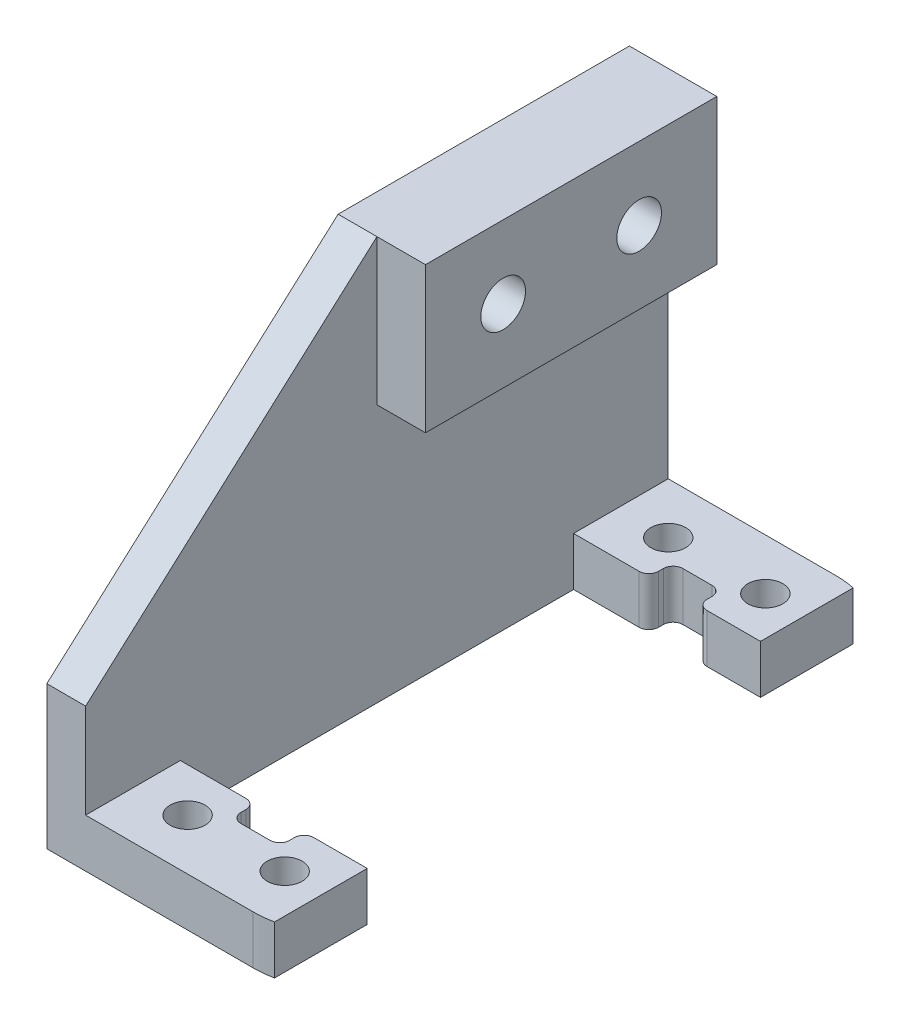
from build123d import *

# Parameters (mm, degrees)
SKETCH1_W           = 50
SKETCH1_H           = 60
BOSS_EXTRUDE1_DEPTH = 5
SKETCH2_W           = 20.5
SKETCH2_H           = 40.5
CUT_EXTRUDE1_DEPTH  = 5
SKETCH3_R           = 1.8
CUT_EXTRUDE2_DEPTH  = 5
SKETCH4_R           = 2.5
CUT_EXTRUDE3_DEPTH  = 5
FILLET1_R           = 10
SKETCH5_W           = 5
SKETCH5_H           = 5
CUT_EXTRUDE4_DEPTH  = 10
FILLET2_R           = 1
SKETCH6_W           = 17.943789306
SKETCH6_H           = 60
CUT_EXTRUDE5_DEPTH  = 10
SKETCH7_W           = 4
SKETCH7_H           = 60
BOSS_EXTRUDE2_DEPTH = 36.6
SKETCH8_W           = 21.864927769
SKETCH8_H           = 69.948880873
CUT_EXTRUDE6_DEPTH  = 24
SKETCH9_W           = 30
SKETCH9_H           = 15
BOSS_EXTRUDE3_DEPTH = 5
CUT_EXTRUDE7_DEPTH  = 5
SKETCH11_R          = 2.3
CUT_EXTRUDE8_DEPTH  = 13


with BuildPart() as part:
    # Sketch1 → Boss-Extrude1 (new body)
    with BuildSketch(Plane(origin=(0, 0, 0), x_dir=(1, 0, 0), z_dir=(0, 1, 0))):
        Rectangle(SKETCH1_W, SKETCH1_H)
    extrude(amount=BOSS_EXTRUDE1_DEPTH)

    # Sketch2 → Cut-Extrude1 (cut)
    with BuildSketch(Plane(origin=(0, 5, 0), x_dir=(1, 0, 0), z_dir=(0, 1, 0))):
        with Locations((8, 0)):
            Rectangle(SKETCH2_W, SKETCH2_H)
    extrude(amount=-CUT_EXTRUDE1_DEPTH, mode=Mode.SUBTRACT)

    # Sketch3 → Cut-Extrude2 (cut)
    with BuildSketch(Plane(origin=(0, 5, 0), x_dir=(1, 0, 0), z_dir=(0, 1, 0))):
        with Locations((3, 24.75)):
            Circle(SKETCH3_R)
        with Locations((13, 24.75)):
            Circle(SKETCH3_R)
        with Locations((13, -24.75)):
            Circle(SKETCH3_R)
        with Locations((3, -24.75)):
            Circle(SKETCH3_R)
    extrude(amount=-CUT_EXTRUDE2_DEPTH, mode=Mode.SUBTRACT)

    # Sketch4 → Cut-Extrude3 (cut)
    with BuildSketch(Plane(origin=(0, 5, 0), x_dir=(1, 0, 0), z_dir=(0, 1, 0))):
        with Locations((-17.5, 20)):
            Circle(SKETCH4_R)
        with Locations((-17.5, -20)):
            Circle(SKETCH4_R)
    extrude(amount=-CUT_EXTRUDE3_DEPTH, mode=Mode.SUBTRACT)

    # Fillet1
    fillet1_edges = [part.edges().sort_by_distance(p)[0] for p in [
        (-25, 2.5, -30),
        (25, 2.5, -30),
        (25, 2.5, 30),
        (-25, 2.5, 30),
    ]]
    fillet(fillet1_edges, radius=FILLET1_R)

    # Sketch5 → Cut-Extrude4 (cut)
    with BuildSketch(Plane(origin=(0, 5, 0), x_dir=(1, 0, 0), z_dir=(0, 1, 0))):
        with Locations((8, 20.25)):
            Rectangle(SKETCH5_W, SKETCH5_H)
    cut_extrude4 = extrude(amount=-CUT_EXTRUDE4_DEPTH, mode=Mode.SUBTRACT)

    # Mirror1: Cut-Extrude4 across plane
    add(cut_extrude4.mirror(Plane.XY), mode=Mode.SUBTRACT)

    # Fillet2
    fillet2_edges = [part.edges().sort_by_distance(p)[0] for p in [
        (10.5, 2.5, 20.25),
        (5.5, 2.5, 20.25),
        (10.5, 2.5, 22.75),
        (5.5, 2.5, 22.75),
        (10.5, 2.5, -20.25),
        (5.5, 2.5, -20.25),
        (5.5, 2.5, -22.75),
        (10.5, 2.5, -22.75),
    ]]
    fillet(fillet2_edges, radius=FILLET2_R)

    # Sketch6 → Cut-Extrude5 (cut)
    with BuildSketch(Plane(origin=(0, 5, 0), x_dir=(1, 0, 0), z_dir=(0, 1, 0))):
        with Locations((25.971894653, 0)):
            Rectangle(SKETCH6_W, SKETCH6_H)
    extrude(amount=-CUT_EXTRUDE5_DEPTH, mode=Mode.SUBTRACT)

    # Sketch7 → Boss-Extrude2 (add)
    with BuildSketch(Plane(origin=(0, 5, 0), x_dir=(1, 0, 0), z_dir=(0, 1, 0))):
        with Locations((-4.25, 0)):
            Rectangle(SKETCH7_W, SKETCH7_H)
    extrude(amount=BOSS_EXTRUDE2_DEPTH)

    # Sketch8 → Cut-Extrude6 (cut)
    with BuildSketch(Plane(origin=(0, 5, 0), x_dir=(1, 0, 0), z_dir=(0, 1, 0))):
        with Locations((-17.182463885, 4.974440436)):
            Rectangle(SKETCH8_W, SKETCH8_H)
    extrude(amount=-CUT_EXTRUDE6_DEPTH, mode=Mode.SUBTRACT)

    # Sketch9 → Boss-Extrude3 (add)
    with BuildSketch(Plane(origin=(-2.25, 0, 0), x_dir=(0, 0, -1), z_dir=(1, 0, 0))):
        with Locations((15, 34.1)):
            Rectangle(SKETCH9_W, SKETCH9_H)
    extrude(amount=BOSS_EXTRUDE3_DEPTH)

    # Sketch10 → Cut-Extrude7 (cut)
    with BuildSketch(Plane(origin=(-2.25, 0, 0), x_dir=(0, 0, -1), z_dir=(1, 0, 0))):
        Polygon((0, 41.6), (-30, 14.728132264), (-30, 41.6), align=None)
    extrude(amount=-CUT_EXTRUDE7_DEPTH, mode=Mode.SUBTRACT)

    # Sketch11 → Cut-Extrude8 (cut)
    with BuildSketch(Plane(origin=(2.75, 0, 0), x_dir=(0, 0, -1), z_dir=(1, 0, 0))):
        with Locations((8, 34.1)):
            Circle(SKETCH11_R)
        with Locations((22, 34.1)):
            Circle(SKETCH11_R)
    extrude(amount=-CUT_EXTRUDE8_DEPTH, mode=Mode.SUBTRACT)


solid = part.part
